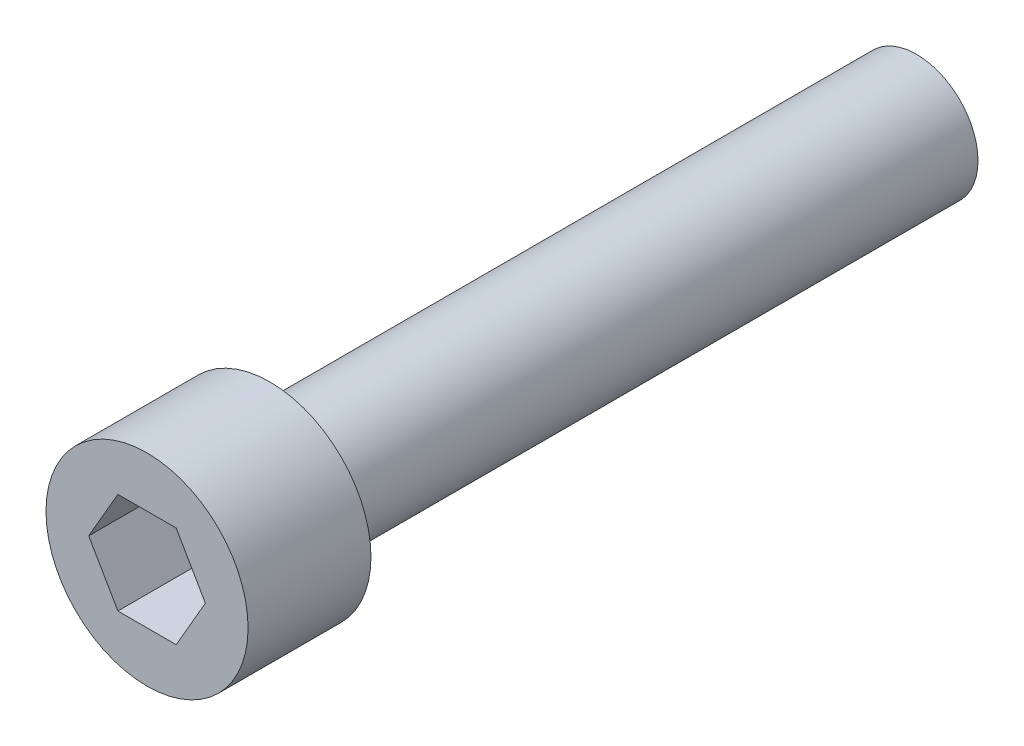
from build123d import *

# Parameters (mm, degrees)
SKETCH1_R           = 2.413
BOSS_EXTRUDE1_DEPTH = 25.4
SKETCH2_R           = 3.96875
BOSS_EXTRUDE2_DEPTH = 4.826
CUT_EXTRUDE1_DEPTH  = 3.81


with BuildPart() as part:
    # Sketch1 → Boss-Extrude1 (new body)
    with BuildSketch(Plane.XY):
        Circle(SKETCH1_R)
    extrude(amount=BOSS_EXTRUDE1_DEPTH)

    # Sketch2 → Boss-Extrude2 (add)
    with BuildSketch(Plane.XY.offset(25.4)):
        Circle(SKETCH2_R)
    extrude(amount=BOSS_EXTRUDE2_DEPTH)

    # Sketch3 → Cut-Extrude1 (cut)
    with BuildSketch(Plane.XY.offset(30.226)):
        Polygon((2.291358881, 0), (1.14567944, 1.984375), (-1.14567944, 1.984375), (-2.291358881, 0), (-1.14567944, -1.984375), (1.14567944, -1.984375), align=None)
    extrude(amount=-CUT_EXTRUDE1_DEPTH, mode=Mode.SUBTRACT)


solid = part.part
